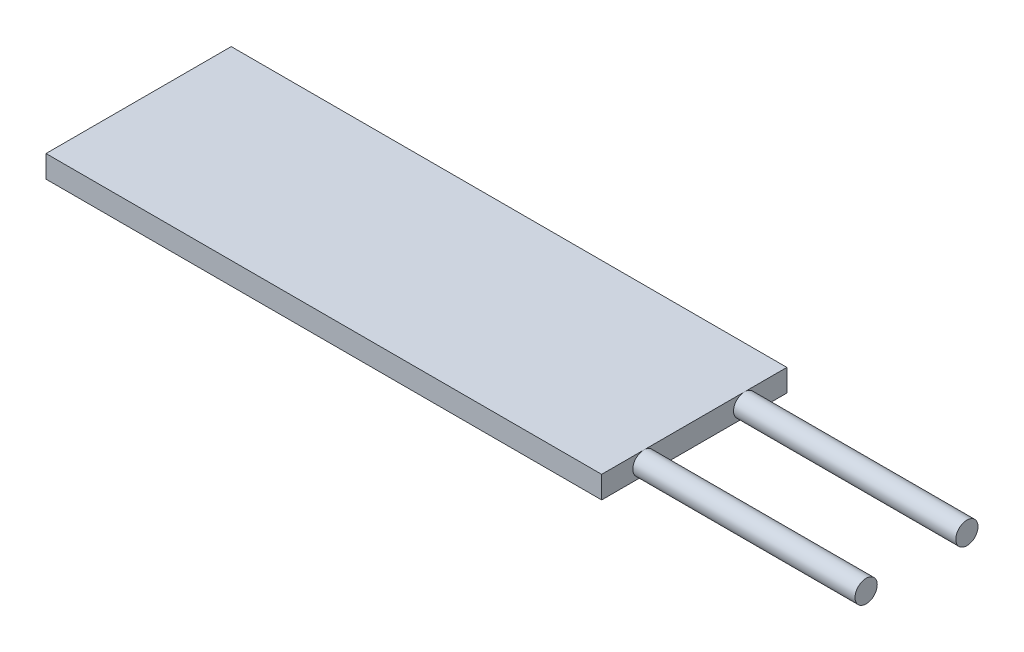
from build123d import *

# Parameters (mm, degrees)
SKETCH1_W           = 25
SKETCH1_H           = 3
BOSS_EXTRUDE1_DEPTH = 75
SKETCH2_R           = 1.5
BOSS_EXTRUDE2_DEPTH = 30


with BuildPart() as part:
    # Sketch1 → Boss-Extrude1 (new body)
    with BuildSketch(Plane(origin=(0, 0, 0), x_dir=(0, 0, -1), z_dir=(1, 0, 0))):
        Rectangle(SKETCH1_W, SKETCH1_H)
    extrude(amount=BOSS_EXTRUDE1_DEPTH)

    # Sketch2 → Boss-Extrude2 (add)
    with BuildSketch(Plane(origin=(75, 0, 0), x_dir=(0, 0, -1), z_dir=(1, 0, 0))):
        with Locations((-6.8, 0)):
            Circle(SKETCH2_R)
        with Locations((6.8, 0)):
            Circle(SKETCH2_R)
    extrude(amount=BOSS_EXTRUDE2_DEPTH)


solid = part.part
